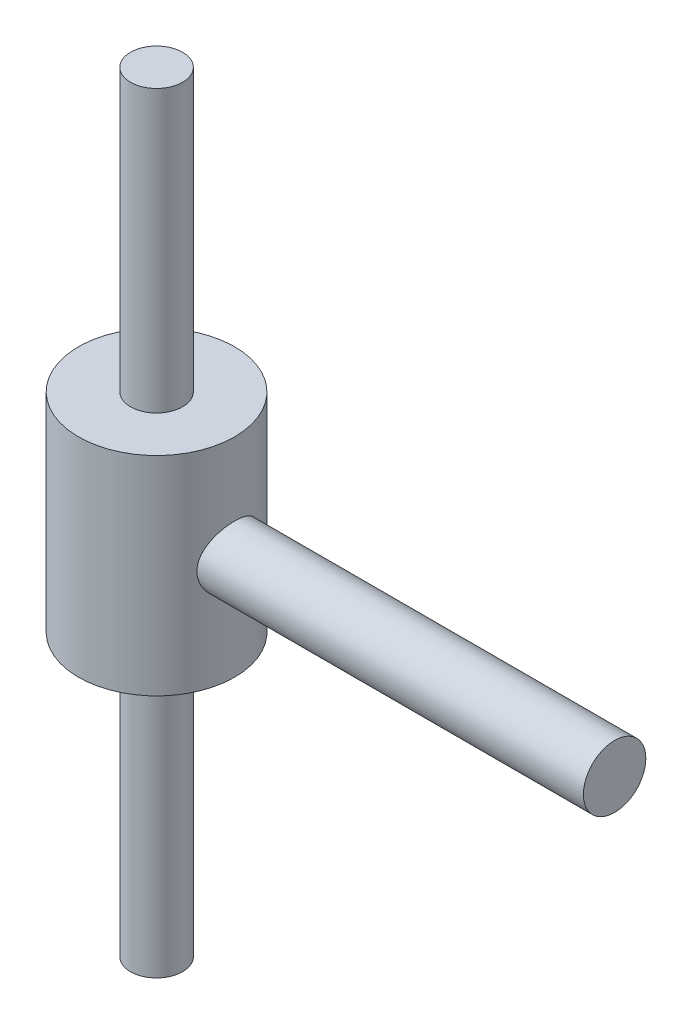
from build123d import *

# Parameters (mm, degrees)
SWEEP2_PROFILE_R = 15
SWEEP3_PROFILE_R = 6
SWEEP4_PROFILE_R = 5
SWEEP5_PROFILE_R = 5


with BuildPart() as part:
    # Sweep2: sweep along a path in Sketch1
    with BuildLine(Plane.XY) as sweep2_path:
        Line((0, 20), (0, -20))
    # Sweep2 profile (on start of the path) → Sweep2 (sweep)
    with BuildSketch(Plane(origin=(0, 20, 0), x_dir=(-1, 0, 0), z_dir=(0, -1, 0))):
        Circle(SWEEP2_PROFILE_R)
    sweep(path=sweep2_path.line)

    # Sweep3: sweep along a path in Sketch30
    with BuildLine(Plane.XY) as sweep3_path:
        Line((0, 0), (88, 0))
    # Sweep3 profile (on start of the path) → Sweep3 (sweep)
    with BuildSketch(Plane(origin=(0, 0, 0), x_dir=(0, 0, 1), z_dir=(1, 0, 0))):
        Circle(SWEEP3_PROFILE_R)
    sweep(path=sweep3_path.line)

    # Sweep4: sweep along a path in Sketch39
    with BuildLine(Plane.XY) as sweep4_path:
        Line((0, -20), (0, -74))
    # Sweep4 profile (on start of the path) → Sweep4 (sweep)
    with BuildSketch(Plane(origin=(0, -20, 0), x_dir=(0, 0, -1), z_dir=(0, -1, 0))):
        Circle(SWEEP4_PROFILE_R)
    sweep(path=sweep4_path.line)

    # Sweep5: sweep along a path in Sketch45
    with BuildLine(Plane.XY) as sweep5_path:
        Line((0, 20), (0, 74))
    # Sweep5 profile (on start of the path) → Sweep5 (sweep)
    with BuildSketch(Plane.ZX.offset(20)):
        Circle(SWEEP5_PROFILE_R)
    sweep(path=sweep5_path.line)


solid = part.part
